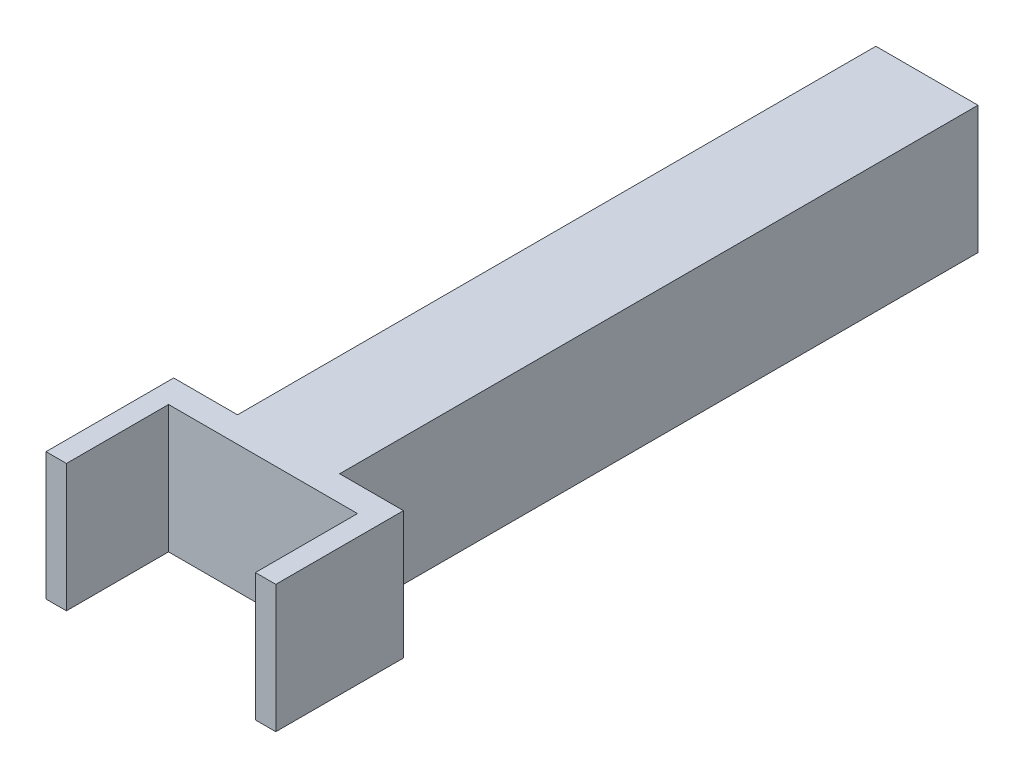
from build123d import *

# Parameters (mm, degrees)
SZKIC1_W                    = 40
SZKIC1_H                    = 50
DODANIE_WYCI_GNI_CIE1_DEPTH = 250
SZKIC2_W                    = 90
SZKIC2_H                    = 50
DODANIE_WYCI_GNI_CIE2_DEPTH = 10
SZKIC3_W                    = 8
SZKIC3_H                    = 50
DODANIE_WYCI_GNI_CIE3_DEPTH = 40


with BuildPart() as part:
    # Szkic1 → Dodanie-wyciągnięcie1 (new body)
    with BuildSketch(Plane.XY):
        Rectangle(SZKIC1_W, SZKIC1_H)
    extrude(amount=DODANIE_WYCI_GNI_CIE1_DEPTH)

    # Szkic2 → Dodanie-wyciągnięcie2 (add)
    with BuildSketch(Plane.XY.offset(250)):
        Rectangle(SZKIC2_W, SZKIC2_H)
    extrude(amount=DODANIE_WYCI_GNI_CIE2_DEPTH)

    # Szkic3 → Dodanie-wyciągnięcie3 (add)
    with BuildSketch(Plane.XY.offset(260)):
        with Locations((-41, 0)):
            Rectangle(SZKIC3_W, SZKIC3_H)
        with Locations((41, 0)):
            Rectangle(SZKIC3_W, SZKIC3_H)
    extrude(amount=DODANIE_WYCI_GNI_CIE3_DEPTH)


solid = part.part
